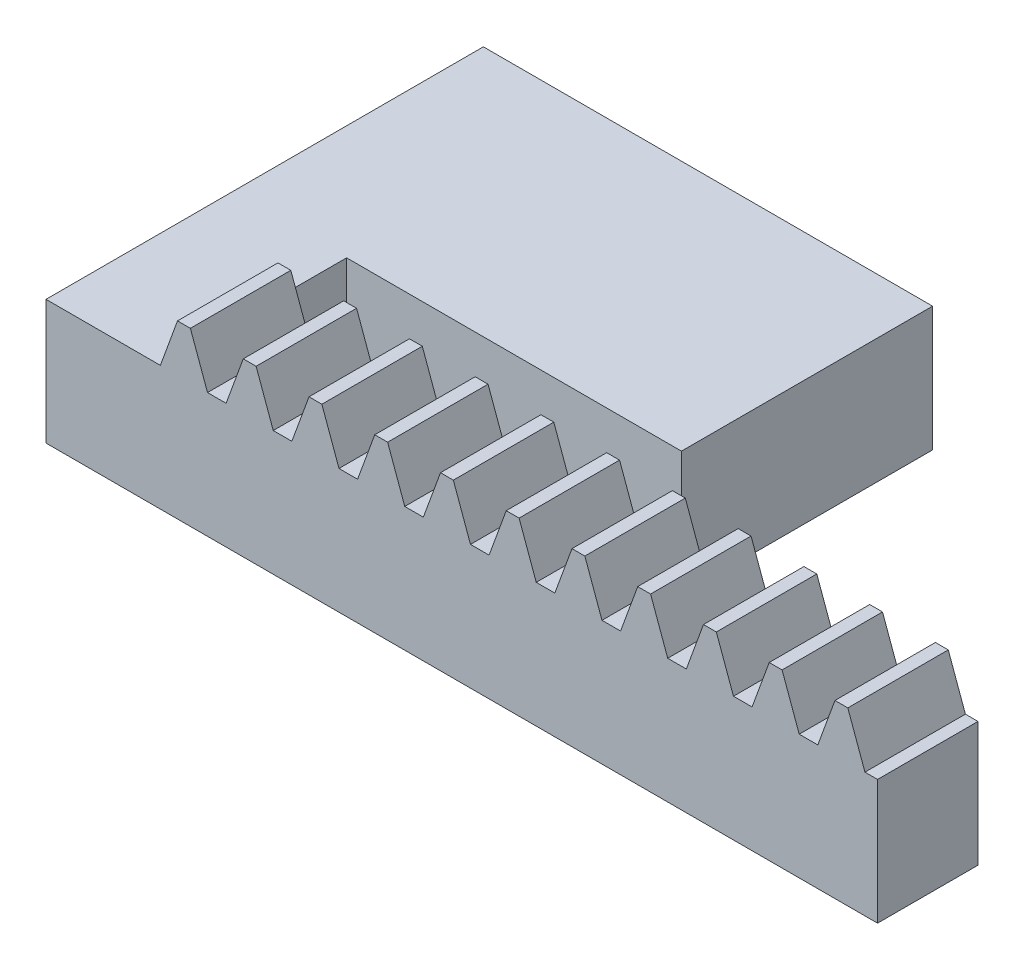
from build123d import *

# Parameters (mm, degrees)
BLANKSKE_W          = 53
BLANKSKE_H          = 8.2
BLANK_DEPTH         = 5
TOOTHCUTSIM_DEPTH   = 54.863159952
TEETHCUTS_COUNT     = 18
TEETHCUTS_PITCH     = 3.14159265
SKETCH2_W           = 6.72762067
SKETCH2_H           = 5.95
BOSS_EXTRUDE1_DEPTH = 20
SKETCH3_W           = 12
SKETCH3_H           = 5.95
BOSS_EXTRUDE2_DEPTH = 16
SKETCH4_W           = 6.72762067
SKETCH4_H           = 5.95
CUT_EXTRUDE1_DEPTH  = 4
SKETCH7_W           = 12.002
SKETCH7_H           = 8.2
CUT_EXTRUDE3_DEPTH  = 9.55
SKETCH9_W           = 1.263
SKETCH9_H           = 21
CUT_EXTRUDE4_DEPTH  = 9.55
SKETCH10_W          = 4.57574993
SKETCH10_H          = 2.726704985
CUT_EXTRUDE6_DEPTH  = 9.55
BLANKSKE_2_W        = 53
BLANKSKE_2_H        = 8.2
CUT_EXTRUDE7_DEPTH  = 0.1
SKETCH11_W          = 34.27037933
SKETCH11_H          = 11.830057098
CUT_EXTRUDE8_DEPTH  = 0.1


with BuildPart() as part:
    # BlankSke → Blank (new body)
    with BuildSketch(Plane.XY):
        with Locations((26.5, 4.1)):
            Rectangle(BLANKSKE_W, BLANKSKE_H)
    extrude(amount=-BLANK_DEPTH)

    # TooCutSkeSim → ToothCutSim (cut, through all)
    with BuildSketch(Plane.XY):
        Polygon((0.44443537, 5.95), (-0.44443537, 5.95), (-1.272613241, 8.2254), (1.272613241, 8.2254), align=None)
    toothcutsim = extrude(amount=-TOOTHCUTSIM_DEPTH, mode=Mode.SUBTRACT)

    # TeethCuts: ToothCutSim ×18
    with Locations(*[(i * TEETHCUTS_PITCH, 0, 0) for i in range(1, TEETHCUTS_COUNT)]):
        add(toothcutsim, mode=Mode.SUBTRACT)

    # Sketch2 → Boss-Extrude1 (add)
    with BuildSketch(Plane(origin=(0, 0, -5), x_dir=(-1, 0, 0), z_dir=(0, 0, -1))):
        with Locations((-3.363810335, 2.975)):
            Rectangle(SKETCH2_W, SKETCH2_H)
    extrude(amount=BOSS_EXTRUDE1_DEPTH)

    # Sketch3 → Boss-Extrude2 (add)
    with BuildSketch(Plane(origin=(6.72762067, 0, 0), x_dir=(0, 0, -1), z_dir=(1, 0, 0))):
        with Locations((15, 2.975)):
            Rectangle(SKETCH3_W, SKETCH3_H)
    extrude(amount=BOSS_EXTRUDE2_DEPTH)

    # Sketch4 → Cut-Extrude1 (cut)
    with BuildSketch(Plane(origin=(0, 0, -25), x_dir=(-1, 0, 0), z_dir=(0, 0, -1))):
        with Locations((-3.363810335, 2.975)):
            Rectangle(SKETCH4_W, SKETCH4_H)
    extrude(amount=-CUT_EXTRUDE1_DEPTH, mode=Mode.SUBTRACT)

    # Sketch7 → Cut-Extrude3 (cut)
    with BuildSketch(Plane(origin=(0, 0, -5), x_dir=(-1, 0, 0), z_dir=(0, 0, -1))):
        with Locations((-46.999, 4.1)):
            Rectangle(SKETCH7_W, SKETCH7_H)
    extrude(amount=-CUT_EXTRUDE3_DEPTH, mode=Mode.SUBTRACT)

    # Sketch9 → Cut-Extrude4 (cut)
    with BuildSketch(Plane.XZ):
        with Locations((0.6315, -10.5)):
            Rectangle(SKETCH9_W, SKETCH9_H)
    extrude(amount=-CUT_EXTRUDE4_DEPTH, mode=Mode.SUBTRACT)

    # Sketch10 → Cut-Extrude6 (cut)
    with BuildSketch(Plane.XY):
        with Locations((3.550874965, 7.313352492)):
            Rectangle(SKETCH10_W, SKETCH10_H)
    extrude(amount=-CUT_EXTRUDE6_DEPTH, mode=Mode.SUBTRACT)

    # BlankSke_2 → Cut-Extrude7 (cut)
    with BuildSketch(Plane.XY):
        with Locations((26.5, 4.1)):
            Rectangle(BLANKSKE_2_W, BLANKSKE_2_H)
    extrude(amount=-CUT_EXTRUDE7_DEPTH, mode=Mode.SUBTRACT)

    # Sketch11 → Cut-Extrude8 (cut)
    with BuildSketch(Plane(origin=(0, 0, -5), x_dir=(-1, 0, 0), z_dir=(0, 0, -1))):
        with Locations((-23.862810335, 5.915028549)):
            Rectangle(SKETCH11_W, SKETCH11_H)
    extrude(amount=-CUT_EXTRUDE8_DEPTH, mode=Mode.SUBTRACT)


solid = part.part
